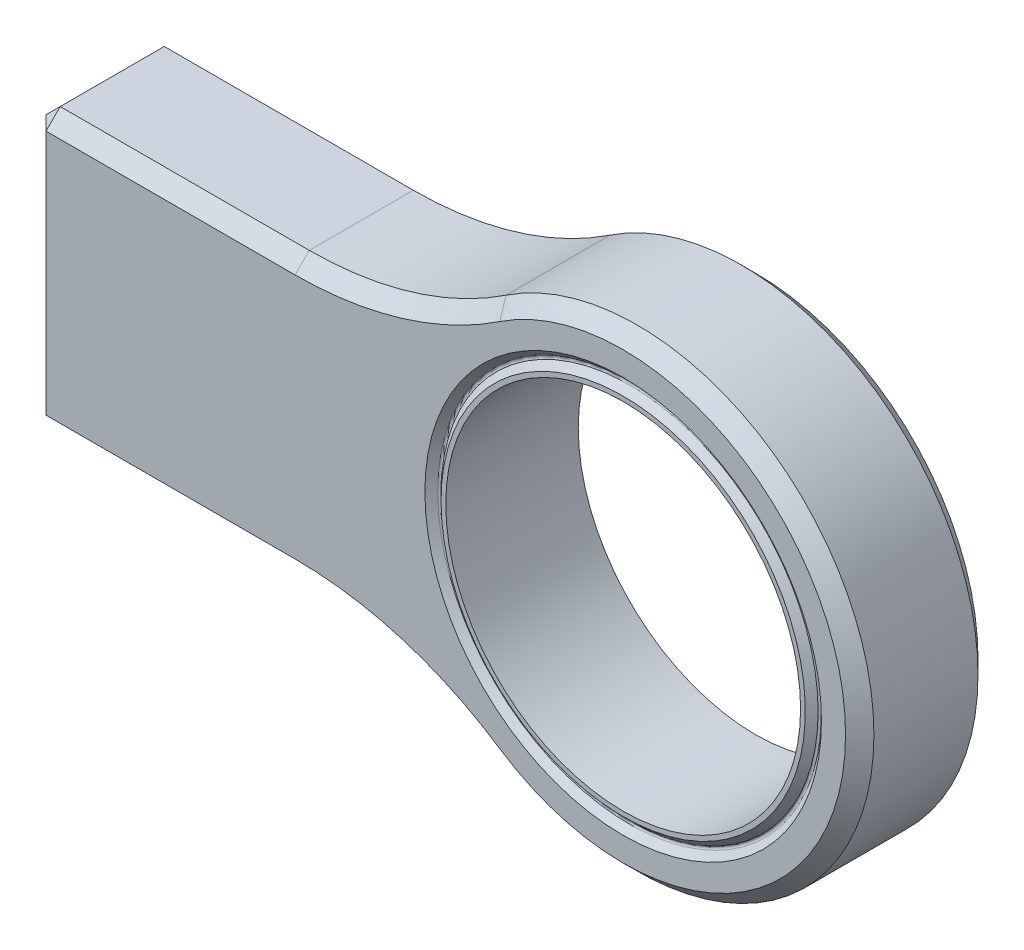
from build123d import *

# Parameters (mm, degrees)
SKETCH1_R           = 9.525
BOSS_EXTRUDE1_DEPTH = 3.556
FILLET1_R           = 19.05
CHAMFER2_SIZE       = 0.762


with BuildPart() as part:
    # Sketch1 → Boss-Extrude1 (new, symmetric)
    with BuildSketch(Plane.XY):
        with BuildLine():
            Line((-31.75, 7.366), (-31.75, -7.366))
            Line((-31.75, -7.366), (-10.345629222, -7.366))
            ThreePointArc((-10.345629222, -7.366), (12.7, 0), (-10.345629222, 7.366))
            Line((-10.345629222, 7.366), (-31.75, 7.366))
        make_face()
        Circle(SKETCH1_R, mode=Mode.SUBTRACT)
    extrude(amount=BOSS_EXTRUDE1_DEPTH, both=True)

    # Fillet1
    fillet1_edges = [part.edges().sort_by_distance(p)[0] for p in [
        (-10.345629222, 7.366, 0),
        (-10.345629222, -7.366, 0),
    ]]
    fillet(fillet1_edges, radius=FILLET1_R)

    # Chamfer2
    chamfer2_edges = [part.edges().sort_by_distance(p)[0] for p in [
        (-24.682063131, 7.366, -3.556),
        (-24.682063131, 7.366, 3.556),
        (-12.092911722, 8.183647162, -3.556),
        (-12.092911722, 8.183647162, 3.556),
        (12.7, 0, -3.556),
        (12.7, 0, 3.556),
        (-12.092911722, -8.183647162, -3.556),
        (-12.092911722, -8.183647162, 3.556),
        (-24.682063131, -7.366, -3.556),
        (-31.75, 7.366, 0),
        (-31.75, 0, -3.556),
        (-31.75, -7.366, 0),
        (-31.75, 0, 3.556),
        (-24.682063131, -7.366, 3.556),
    ]]
    chamfer(chamfer2_edges, length=CHAMFER2_SIZE)

    # Sketch2 → Cut-Revolve1 (revolve, cut)
    with BuildSketch(Plane(origin=(0, 0, 0), x_dir=(1, 0, 0), z_dir=(0, 1, 0))):
        with BuildLine():
            Line((10.646210245, 3.556), (10.302407684, 3.212197439))
            ThreePointArc((10.302407684, 3.212197439), (10.212605122, 3.175), (10.122802561, 3.212197439))
            Line((10.122802561, 3.212197439), (9.779, 3.556))
            Line((9.779, 3.556), (10.646210245, 3.556))
        make_face()
    cut_revolve1 = revolve(axis=Axis((0, 0, -14.192615474), (0, 0, 1)), mode=Mode.SUBTRACT)

    # Mirror1: Cut-Revolve1 across plane
    add(cut_revolve1.mirror(Plane.XY), mode=Mode.SUBTRACT)


solid = part.part
